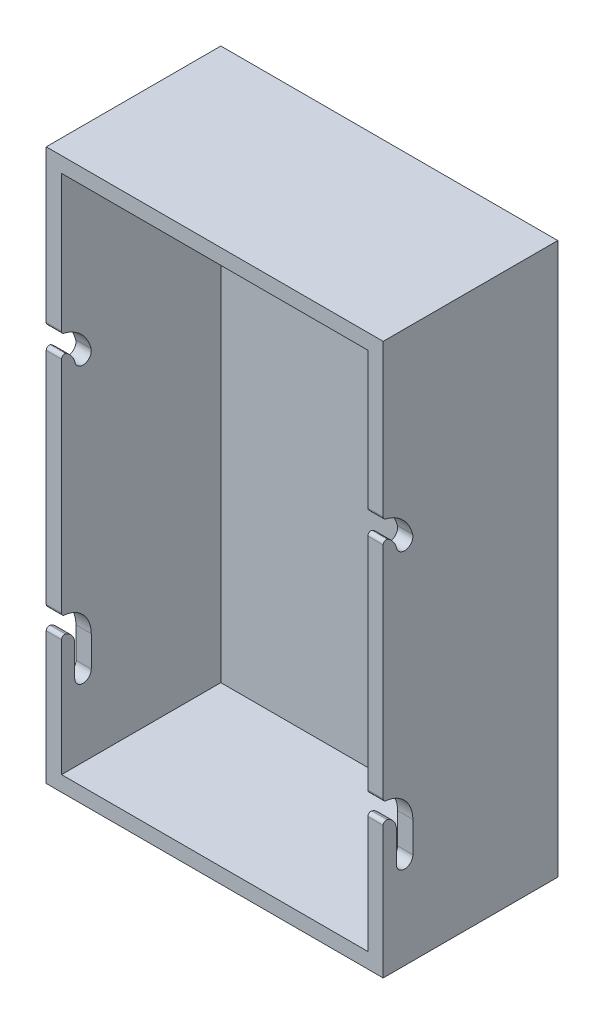
from build123d import *

# Parameters (mm, degrees)
ESQUISSE1_W             = 110
ESQUISSE1_H             = 180
ESQUISSE1_W_2           = 100
ESQUISSE1_H_2           = 170
BOSS_EXTRU_1_DEPTH      = 57
ESQUISSE2_W             = 110
ESQUISSE2_H             = 180
BOSS_EXTRU_2_DEPTH      = 5
ENL_V_MAT_EXTRU_1_DEPTH = 111
CONG_1_R                = 1


with BuildPart() as part:
    # Esquisse1 → Boss.-Extru.1 (new body)
    with BuildSketch(Plane.XY):
        with Locations((55, 90)):
            Rectangle(ESQUISSE1_W, ESQUISSE1_H)
        with Locations((55, 90)):
            Rectangle(ESQUISSE1_W_2, ESQUISSE1_H_2, mode=Mode.SUBTRACT)
    extrude(amount=BOSS_EXTRU_1_DEPTH)

    # Esquisse2 → Boss.-Extru.2 (add)
    with BuildSketch(Plane(origin=(0, 0, 0), x_dir=(-1, 0, 0), z_dir=(0, 0, -1))):
        with Locations((-55, 90)):
            Rectangle(ESQUISSE2_W, ESQUISSE2_H)
    extrude(amount=-BOSS_EXTRU_2_DEPTH)

    # Esquisse3 → Enlèv. mat.-Extru.1 (cut, through all)
    with BuildSketch(Plane.ZY):
        with BuildLine():
            ThreePointArc((52.62207614, 119.356014971), (54.199469032, 122.258730766), (57, 124.011144421))
            Line((57, 124.011144421), (57, 129.5))
            ThreePointArc((57, 129.5), (56.714535858, 129.484866891), (56.432271686, 129.439637203))
            ThreePointArc((56.432271686, 129.439637203), (50.642732019, 126.341305275), (47.37792386, 120.643985029))
            ThreePointArc((47.37792386, 120.643985029), (49.356014971, 117.37792386), (52.62207614, 119.356014971))
        make_face()
        with BuildLine():
            Line((57, 129.5), (57, 124.011144421))
            ThreePointArc((57, 124.011144421), (57.282178821, 124.092165775), (57.567728314, 124.160362797))
            ThreePointArc((57.567728314, 124.160362797), (59.684866891, 127.085464142), (57, 129.5))
        make_face()
        with BuildLine():
            ThreePointArc((47.3, 40), (50, 42.7), (52.7, 40))
            ThreePointArc((52.7, 40), (53.959440841, 43.040559159), (57, 44.3))
            Line((57, 44.3), (57, 49.7))
            ThreePointArc((57, 49.7), (50.141064222, 46.858935778), (47.3, 40))
        make_face()
        with BuildLine():
            Line((57, 49.7), (57, 44.3))
            ThreePointArc((57, 44.3), (59.7, 47), (57, 49.7))
        make_face()
        with BuildLine():
            ThreePointArc((47.3, 40), (50, 37.3), (52.7, 40))
            ThreePointArc((52.7, 40), (50, 42.7), (47.3, 40))
        make_face()
        with BuildLine():
            Line((47.3, 40), (47.3, 30))
            ThreePointArc((47.3, 30), (50, 27.3), (52.7, 30))
            Line((52.7, 30), (52.7, 40))
            ThreePointArc((52.7, 40), (50, 37.3), (47.3, 40))
        make_face()
    extrude(amount=-ENL_V_MAT_EXTRU_1_DEPTH, mode=Mode.SUBTRACT)

    # Congé1
    cong_1_edges = [part.edges().sort_by_distance(p)[0] for p in [
        (2.5, 49.7, 57),
        (107.5, 49.7, 57),
        (107.5, 44.3, 57),
        (2.5, 44.3, 57),
        (2.5, 124.011144421, 57),
        (2.5, 129.5, 57),
        (107.5, 124.011144421, 57),
        (107.5, 129.5, 57),
    ]]
    fillet(cong_1_edges, radius=CONG_1_R)


solid = part.part
